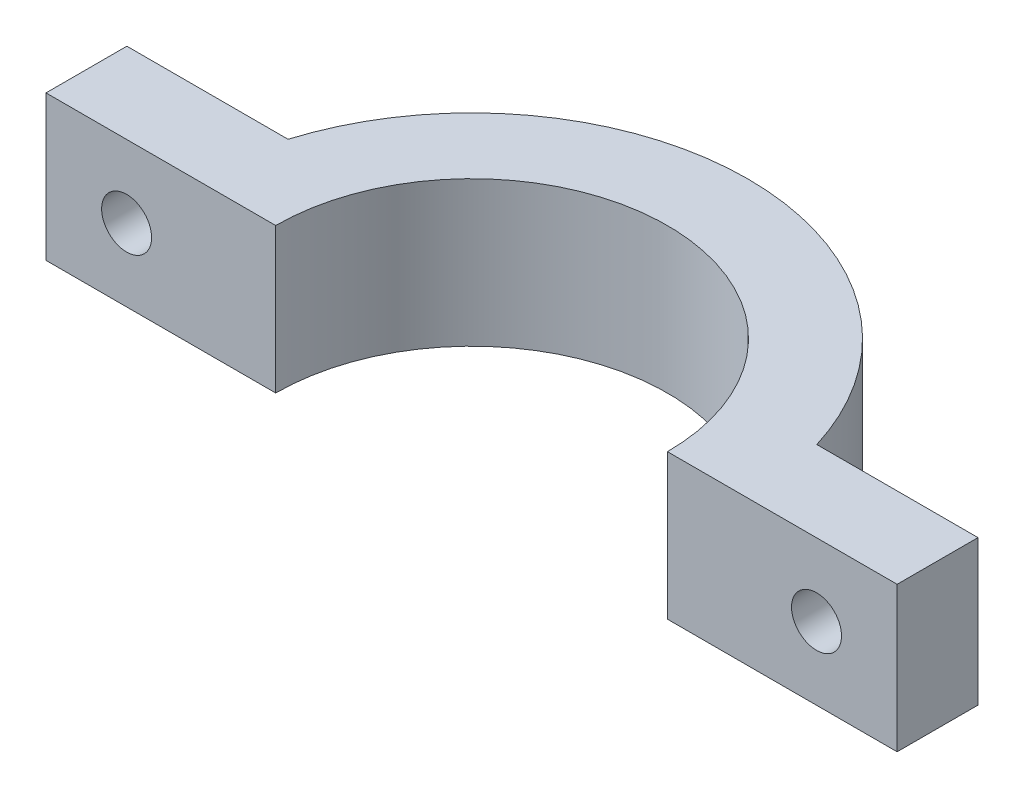
from build123d import *

# Parameters (mm, degrees)
BOSS_EXTRUDE1_DEPTH = 9
SKETCH2_R           = 1.55
CUT_EXTRUDE1_DEPTH  = 9


with BuildPart() as part:
    # Sketch1 → Boss-Extrude1 (new body)
    with BuildSketch(Plane(origin=(0, 0, 0), x_dir=(1, 0, 0), z_dir=(0, 1, 0))):
        with BuildLine():
            Line((16.4, 5.016223679), (26.4, 5.016223679))
            Line((26.4, 5.016223679), (26.4, 0))
            Line((26.4, 0), (12.15, 0))
            ThreePointArc((12.15, 0), (0, 12.15), (-12.15, 0))
            Line((-12.15, 0), (-26.4, 0))
            Line((-26.4, 0), (-26.4, 5.016223679))
            Line((-26.4, 5.016223679), (-16.4, 5.016223679))
            ThreePointArc((-16.4, 5.016223679), (0, 17.15), (16.4, 5.016223679))
        make_face()
    extrude(amount=BOSS_EXTRUDE1_DEPTH)

    # Sketch2 → Cut-Extrude1 (cut)
    with BuildSketch(Plane(origin=(0, 0, -5.016223679), x_dir=(-1, 0, 0), z_dir=(0, 0, -1))):
        with Locations((-21.4, 4.5)):
            Circle(SKETCH2_R)
    cut_extrude1 = extrude(amount=-CUT_EXTRUDE1_DEPTH, mode=Mode.SUBTRACT)

    # Mirror1: Cut-Extrude1 across plane
    add(cut_extrude1.mirror(Plane(origin=(0, 0, 0), x_dir=(0, 0, 1), z_dir=(1, 0, 0))), mode=Mode.SUBTRACT)


solid = part.part
